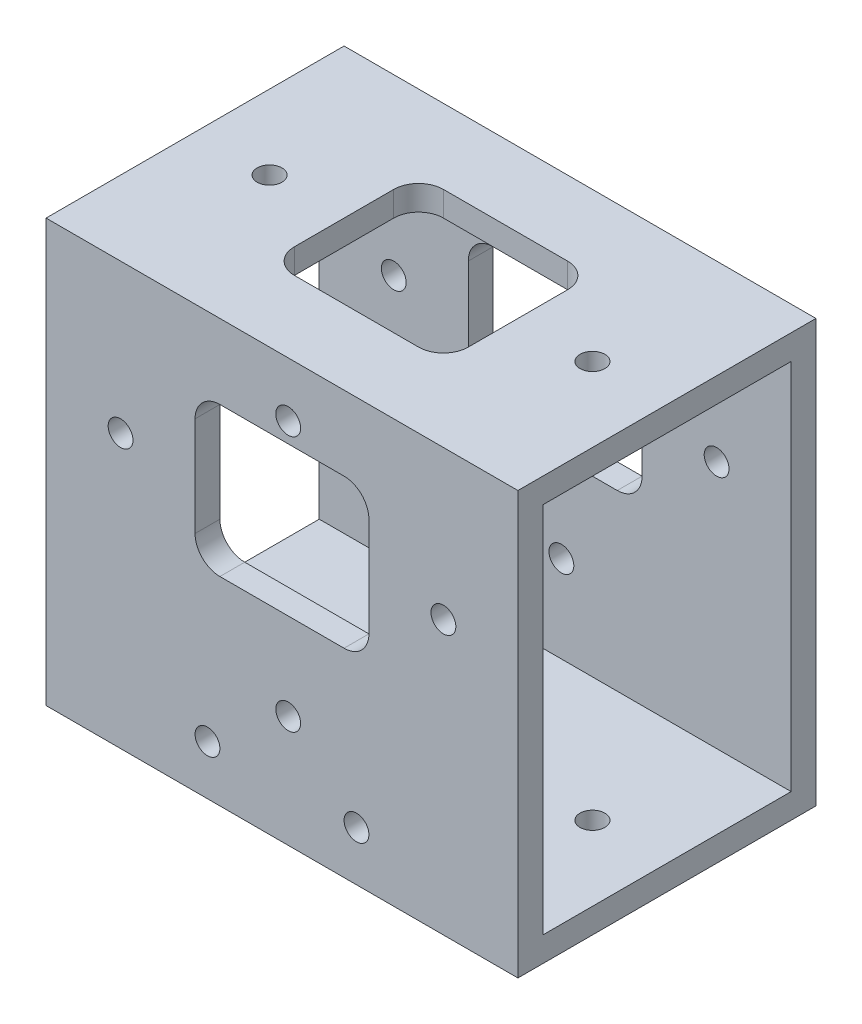
from build123d import *

# Parameters (mm, degrees)
SKETCH1_W                        = 190
SKETCH1_H                        = 120
BOSS_EXTRUDE1_DEPTH              = 170
SKETCH2_W                        = 50
SKETCH2_H                        = 75
CUT_EXTRUDE1_DEPTH               = 190
CUT_EXTRUDE2_DEPTH               = 15
CUT_EXTRUDE3_DEPTH               = 15
CUT_EXTRUDE4_DEPTH               = 15
M10X1_0_TAPPED_HOLE1_D           = 9
M10X1_0_TAPPED_HOLE1_DEPTH       = 23
M10X1_0_TAPPED_HOLE1_CBORE_D     = 10
M10X1_0_TAPPED_HOLE1_CBORE_DEPTH = 20
M10X1_0_TAPPED_HOLE1_TIP         = 2.703872786
M10X1_0_TAPPED_HOLE2_D           = 9
M10X1_0_TAPPED_HOLE2_DEPTH       = 23
M10X1_0_TAPPED_HOLE2_CBORE_D     = 10
M10X1_0_TAPPED_HOLE2_CBORE_DEPTH = 20
M10X1_0_TAPPED_HOLE2_TIP         = 2.703872786
M10X1_0_TAPPED_HOLE3_D           = 9
M10X1_0_TAPPED_HOLE3_DEPTH       = 23
M10X1_0_TAPPED_HOLE3_CBORE_D     = 10
M10X1_0_TAPPED_HOLE3_CBORE_DEPTH = 20
M10X1_0_TAPPED_HOLE3_TIP         = 2.703872786
M10X1_0_TAPPED_HOLE4_D           = 9
M10X1_0_TAPPED_HOLE4_DEPTH       = 23
M10X1_0_TAPPED_HOLE4_CBORE_D     = 10
M10X1_0_TAPPED_HOLE4_CBORE_DEPTH = 20
M10X1_0_TAPPED_HOLE4_TIP         = 2.703872786
M10X1_0_TAPPED_HOLE5_D           = 9
M10X1_0_TAPPED_HOLE5_DEPTH       = 23
M10X1_0_TAPPED_HOLE5_CBORE_D     = 10
M10X1_0_TAPPED_HOLE5_CBORE_DEPTH = 20
M10X1_0_TAPPED_HOLE5_TIP         = 2.703872786


with BuildPart() as part:
    # Sketch1 → Boss-Extrude1 (new body)
    with BuildSketch(Plane(origin=(0, 0, 0), x_dir=(1, 0, 0), z_dir=(0, 1, 0))):
        Rectangle(SKETCH1_W, SKETCH1_H)
    extrude(amount=BOSS_EXTRUDE1_DEPTH)

    # Sketch2 → Cut-Extrude1 (cut)
    with BuildSketch(Plane(origin=(95, 0, 0), x_dir=(0, 0, -1), z_dir=(1, 0, 0))):
        with Locations((-25, 122.5)):
            Rectangle(SKETCH2_W, SKETCH2_H)
        with Locations((25, 122.5)):
            Rectangle(SKETCH2_W, SKETCH2_H)
        with Locations((25, 47.5)):
            Rectangle(SKETCH2_W, SKETCH2_H)
        with Locations((-25, 47.5)):
            Rectangle(SKETCH2_W, SKETCH2_H)
    extrude(amount=-CUT_EXTRUDE1_DEPTH, mode=Mode.SUBTRACT)

    # Sketch3 → Cut-Extrude2 (cut)
    with BuildSketch(Plane.XY.offset(60)):
        with BuildLine():
            Line((-25, 80), (25, 80))
            ThreePointArc((25, 80), (32.071067812, 82.928932188), (35, 90))
            Line((35, 90), (35, 130))
            ThreePointArc((35, 130), (32.071067812, 137.071067812), (25, 140))
            Line((25, 140), (-25, 140))
            ThreePointArc((-25, 140), (-32.071067812, 137.071067812), (-35, 130))
            Line((-35, 130), (-35, 90))
            ThreePointArc((-35, 90), (-32.071067812, 82.928932188), (-25, 80))
        make_face()
    extrude(amount=-CUT_EXTRUDE2_DEPTH, mode=Mode.SUBTRACT)

    # Sketch4 → Cut-Extrude3 (cut)
    with BuildSketch(Plane(origin=(0, 0, -60), x_dir=(-1, 0, 0), z_dir=(0, 0, -1))):
        with BuildLine():
            Line((-25, 80), (25, 80))
            ThreePointArc((25, 80), (32.071067812, 82.928932188), (35, 90))
            Line((35, 90), (35, 130))
            ThreePointArc((35, 130), (32.071067812, 137.071067812), (25, 140))
            Line((25, 140), (-25, 140))
            ThreePointArc((-25, 140), (-32.071067812, 137.071067812), (-35, 130))
            Line((-35, 130), (-35, 90))
            ThreePointArc((-35, 90), (-32.071067812, 82.928932188), (-25, 80))
        make_face()
    extrude(amount=-CUT_EXTRUDE3_DEPTH, mode=Mode.SUBTRACT)

    # Sketch5 → Cut-Extrude4 (cut)
    with BuildSketch(Plane(origin=(0, 170, 0), x_dir=(1, 0, 0), z_dir=(0, 1, 0))):
        with BuildLine():
            Line((-25, -30), (25, -30))
            ThreePointArc((25, -30), (32.071067812, -27.071067812), (35, -20))
            Line((35, -20), (35, 20))
            ThreePointArc((35, 20), (32.071067812, 27.071067812), (25, 30))
            Line((25, 30), (-25, 30))
            ThreePointArc((-25, 30), (-32.071067812, 27.071067812), (-35, 20))
            Line((-35, 20), (-35, -20))
            ThreePointArc((-35, -20), (-32.071067812, -27.071067812), (-25, -30))
        make_face()
    extrude(amount=-CUT_EXTRUDE4_DEPTH, mode=Mode.SUBTRACT)

    # M10x1.0 Tapped Hole1
    with Locations(Plane(origin=(65, 110, -70), x_dir=(-1, 0, 0), z_dir=(0, 0, -1))):
        with Locations((0, 0), (130, 0), (62.5, -65)):
            CounterBoreHole(M10X1_0_TAPPED_HOLE1_D / 2, M10X1_0_TAPPED_HOLE1_CBORE_D / 2, M10X1_0_TAPPED_HOLE1_CBORE_DEPTH, depth=M10X1_0_TAPPED_HOLE1_DEPTH)
            with Locations((0, 0, -(M10X1_0_TAPPED_HOLE1_DEPTH + M10X1_0_TAPPED_HOLE1_TIP / 2))):  # 118° drill point
                Cone(0, M10X1_0_TAPPED_HOLE1_D / 2, M10X1_0_TAPPED_HOLE1_TIP, mode=Mode.SUBTRACT)

    # M10x1.0 Tapped Hole2
    with Locations(Plane(origin=(-65, 170, 0), x_dir=(0, 0, 1), z_dir=(0, 1, 0))):
        with Locations((0, 0), (0, 130)):
            CounterBoreHole(M10X1_0_TAPPED_HOLE2_D / 2, M10X1_0_TAPPED_HOLE2_CBORE_D / 2, M10X1_0_TAPPED_HOLE2_CBORE_DEPTH, depth=M10X1_0_TAPPED_HOLE2_DEPTH)
            with Locations((0, 0, -(M10X1_0_TAPPED_HOLE2_DEPTH + M10X1_0_TAPPED_HOLE2_TIP / 2))):  # 118° drill point
                Cone(0, M10X1_0_TAPPED_HOLE2_D / 2, M10X1_0_TAPPED_HOLE2_TIP, mode=Mode.SUBTRACT)

    # M10x1.0 Tapped Hole3
    with Locations(Plane(origin=(-65, 110, 60), x_dir=(1, 0, 0), z_dir=(0, 0, 1))):
        with Locations((0, 0), (130, 0), (67.5, -65), (67.5, 38)):
            CounterBoreHole(M10X1_0_TAPPED_HOLE3_D / 2, M10X1_0_TAPPED_HOLE3_CBORE_D / 2, M10X1_0_TAPPED_HOLE3_CBORE_DEPTH, depth=M10X1_0_TAPPED_HOLE3_DEPTH)
            with Locations((0, 0, -(M10X1_0_TAPPED_HOLE3_DEPTH + M10X1_0_TAPPED_HOLE3_TIP / 2))):  # 118° drill point
                Cone(0, M10X1_0_TAPPED_HOLE3_D / 2, M10X1_0_TAPPED_HOLE3_TIP, mode=Mode.SUBTRACT)

    # M10x1.0 Tapped Hole4
    with Locations(Plane(origin=(65, 0, 0), x_dir=(0, 0, -1), z_dir=(0, -1, 0))):
        with Locations((0, 0), (0, -130)):
            CounterBoreHole(M10X1_0_TAPPED_HOLE4_D / 2, M10X1_0_TAPPED_HOLE4_CBORE_D / 2, M10X1_0_TAPPED_HOLE4_CBORE_DEPTH, depth=M10X1_0_TAPPED_HOLE4_DEPTH)
            with Locations((0, 0, -(M10X1_0_TAPPED_HOLE4_DEPTH + M10X1_0_TAPPED_HOLE4_TIP / 2))):  # 118° drill point
                Cone(0, M10X1_0_TAPPED_HOLE4_D / 2, M10X1_0_TAPPED_HOLE4_TIP, mode=Mode.SUBTRACT)

    # M10x1.0 Tapped Hole5
    with Locations(Plane(origin=(-30, 20, 60), x_dir=(1, 0, 0), z_dir=(0, 0, 1))):
        with Locations((0, 0), (60, 0)):
            CounterBoreHole(M10X1_0_TAPPED_HOLE5_D / 2, M10X1_0_TAPPED_HOLE5_CBORE_D / 2, M10X1_0_TAPPED_HOLE5_CBORE_DEPTH, depth=M10X1_0_TAPPED_HOLE5_DEPTH)
            with Locations((0, 0, -(M10X1_0_TAPPED_HOLE5_DEPTH + M10X1_0_TAPPED_HOLE5_TIP / 2))):  # 118° drill point
                Cone(0, M10X1_0_TAPPED_HOLE5_D / 2, M10X1_0_TAPPED_HOLE5_TIP, mode=Mode.SUBTRACT)


solid = part.part
